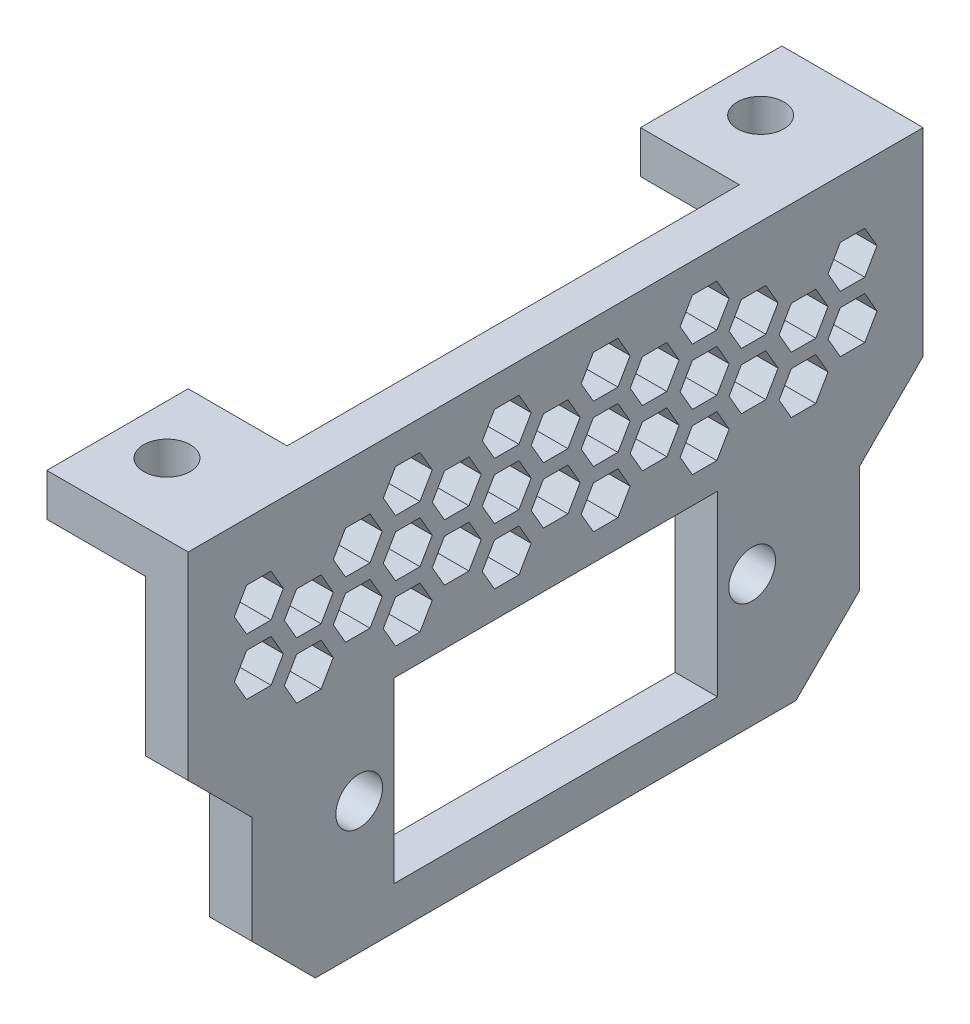
from build123d import *

# Parameters (mm, degrees)
SKETCH1_W           = 34
SKETCH1_H           = 18.6
SKETCH1_R           = 1.65
BOSS_EXTRUDE1_DEPTH = 3
BOSS_EXTRUDE2_DEPTH = 3
SKETCH3_W           = 7
SKETCH3_H           = 10
SKETCH3_R           = 1.65
BOSS_EXTRUDE3_DEPTH = 3
CUT_EXTRUDE1_DEPTH  = 10


with BuildPart() as part:
    # Sketch1 → Boss-Extrude1 (new body)
    with BuildSketch(Plane(origin=(0, 0, 0), x_dir=(0, 0, -1), z_dir=(1, 0, 0))):
        with Locations((0, 6.3)):
            Rectangle(SKETCH1_W, SKETCH1_H)
        with Locations((-13.9, 6.3)):
            Circle(SKETCH1_R, mode=Mode.SUBTRACT)
        Polygon((11.45, 0), (-11.45, 0), (-11.45, 6.3), (-11.45, 12.6), (11.45, 12.6), (11.45, 6.3), align=None, mode=Mode.SUBTRACT)
        with BuildLine():
            ThreePointArc((15.55, 6.3), (13.9, 4.65), (12.25, 6.3))
            ThreePointArc((12.25, 6.3), (13.9, 7.95), (15.55, 6.3))
        make_face(mode=Mode.SUBTRACT)
    extrude(amount=BOSS_EXTRUDE1_DEPTH)

    # Sketch2 → Boss-Extrude2 (add)
    with BuildSketch(Plane.ZY):
        Polygon((-21.5, 9.1), (-21.5, 1.5), (-17, -3), (-17, 15.6), (17, 15.6), (17, -3), (21.5, 1.5), (21.5, 9.1), (26, 13.6), (26, 27.6), (-26, 27.6), (-26, 13.6), align=None)
    extrude(amount=-BOSS_EXTRUDE2_DEPTH)

    # Sketch3 → Boss-Extrude3 (add)
    # profile 1 of 2: a face of its own
    with BuildSketch(Plane(origin=(0, 27.6, 0), x_dir=(1, 0, 0), z_dir=(0, 1, 0))):
        with Locations((-3.5, -21)):
            Rectangle(SKETCH3_W, SKETCH3_H)
        with Locations((-3.5, -21)):
            Circle(SKETCH3_R, mode=Mode.SUBTRACT)
    # profile 2 of 2: a face of its own
    with BuildSketch(Plane(origin=(0, 27.6, 0), x_dir=(1, 0, 0), z_dir=(0, 1, 0))):
        with Locations((-3.5, 21)):
            Rectangle(SKETCH3_W, SKETCH3_H)
        with Locations((-3.5, 21)):
            Circle(SKETCH3_R, mode=Mode.SUBTRACT)
    extrude(amount=-BOSS_EXTRUDE3_DEPTH)

    # Sketch4 → Cut-Extrude1 (cut)
    with BuildSketch(Plane.ZY):
        Polygon((-16.669872981, 18.5), (-15.803847577, 20), (-16.669872981, 21.5), (-18.401923789, 21.5), (-19.267949192, 20), (-18.401923789, 18.5), align=None)
        Polygon((-20.133974596, 16.5), (-19.267949192, 18), (-20.133974596, 19.5), (-21.866025404, 19.5), (-22.732050808, 18), (-21.866025404, 16.5), align=None)
        Polygon((-20.133974596, 20.5), (-19.267949192, 22), (-20.133974596, 23.5), (-21.866025404, 23.5), (-22.732050808, 22), (-21.866025404, 20.5), align=None)
        Polygon((-13.133974596, 16.5), (-12.267949192, 18), (-13.133974596, 19.5), (-14.866025404, 19.5), (-15.732050808, 18), (-14.866025404, 16.5), align=None)
        Polygon((-13.133974596, 20.5), (-12.267949192, 22), (-13.133974596, 23.5), (-14.866025404, 23.5), (-15.732050808, 22), (-14.866025404, 20.5), align=None)
        Polygon((-6.133974596, 16.5), (-5.267949192, 18), (-6.133974596, 19.5), (-7.866025404, 19.5), (-8.732050808, 18), (-7.866025404, 16.5), align=None)
        Polygon((-6.133974596, 20.5), (-5.267949192, 22), (-6.133974596, 23.5), (-7.866025404, 23.5), (-8.732050808, 22), (-7.866025404, 20.5), align=None)
        Polygon((0.866025404, 16.5), (1.732050808, 18), (0.866025404, 19.5), (-0.866025404, 19.5), (-1.732050808, 18), (-0.866025404, 16.5), align=None)
        Polygon((0.866025404, 20.5), (1.732050808, 22), (0.866025404, 23.5), (-0.866025404, 23.5), (-1.732050808, 22), (-0.866025404, 20.5), align=None)
        Polygon((7.866025404, 16.5), (8.732050808, 18), (7.866025404, 19.5), (6.133974596, 19.5), (5.267949192, 18), (6.133974596, 16.5), align=None)
        Polygon((7.866025404, 20.5), (8.732050808, 22), (7.866025404, 23.5), (6.133974596, 23.5), (5.267949192, 22), (6.133974596, 20.5), align=None)
        Polygon((14.866025404, 16.5), (15.732050808, 18), (14.866025404, 19.5), (13.133974596, 19.5), (12.267949192, 18), (13.133974596, 16.5), align=None)
        Polygon((14.866025404, 20.5), (15.732050808, 22), (14.866025404, 23.5), (13.133974596, 23.5), (12.267949192, 22), (13.133974596, 20.5), align=None)
        Polygon((21.866025404, 16.5), (22.732050808, 18), (21.866025404, 19.5), (20.133974596, 19.5), (19.267949192, 18), (20.133974596, 16.5), align=None)
        Polygon((21.866025404, 20.5), (22.732050808, 22), (21.866025404, 23.5), (20.133974596, 23.5), (19.267949192, 22), (20.133974596, 20.5), align=None)
        Polygon((-9.669872981, 18.5), (-8.803847577, 20), (-9.669872981, 21.5), (-11.401923789, 21.5), (-12.267949192, 20), (-11.401923789, 18.5), align=None)
        Polygon((-9.669872981, 22.5), (-8.803847577, 24), (-9.669872981, 25.5), (-11.401923789, 25.5), (-12.267949192, 24), (-11.401923789, 22.5), align=None)
        Polygon((-2.669872981, 18.5), (-1.803847577, 20), (-2.669872981, 21.5), (-4.401923789, 21.5), (-5.267949192, 20), (-4.401923789, 18.5), align=None)
        Polygon((-2.669872981, 22.5), (-1.803847577, 24), (-2.669872981, 25.5), (-4.401923789, 25.5), (-5.267949192, 24), (-4.401923789, 22.5), align=None)
        Polygon((4.330127019, 18.5), (5.196152423, 20), (4.330127019, 21.5), (2.598076211, 21.5), (1.732050808, 20), (2.598076211, 18.5), align=None)
        Polygon((4.330127019, 22.5), (5.196152423, 24), (4.330127019, 25.5), (2.598076211, 25.5), (1.732050808, 24), (2.598076211, 22.5), align=None)
        Polygon((11.330127019, 18.5), (12.196152423, 20), (11.330127019, 21.5), (9.598076211, 21.5), (8.732050808, 20), (9.598076211, 18.5), align=None)
        Polygon((11.330127019, 22.5), (12.196152423, 24), (11.330127019, 25.5), (9.598076211, 25.5), (8.732050808, 24), (9.598076211, 22.5), align=None)
        Polygon((18.330127019, 18.5), (19.196152423, 20), (18.330127019, 21.5), (16.598076211, 21.5), (15.732050808, 20), (16.598076211, 18.5), align=None)
        Polygon((-9.669872981, 14.5), (-8.803847577, 16), (-9.669872981, 17.5), (-11.401923789, 17.5), (-12.267949192, 16), (-11.401923789, 14.5), align=None)
        Polygon((-2.669872981, 14.5), (-1.803847577, 16), (-2.669872981, 17.5), (-4.401923789, 17.5), (-5.267949192, 16), (-4.401923789, 14.5), align=None)
        Polygon((4.330127019, 14.5), (5.196152423, 16), (4.330127019, 17.5), (2.598076211, 17.5), (1.732050808, 16), (2.598076211, 14.5), align=None)
        Polygon((11.330127019, 14.5), (12.196152423, 16), (11.330127019, 17.5), (9.598076211, 17.5), (8.732050808, 16), (9.598076211, 14.5), align=None)
        Polygon((18.330127019, 14.5), (19.196152423, 16), (18.330127019, 17.5), (16.598076211, 17.5), (15.732050808, 16), (16.598076211, 14.5), align=None)
        Polygon((-16.669872981, 14.5), (-15.803847577, 16), (-16.669872981, 17.5), (-18.401923789, 17.5), (-19.267949192, 16), (-18.401923789, 14.5), align=None)
    extrude(amount=-CUT_EXTRUDE1_DEPTH, mode=Mode.SUBTRACT)


solid = part.part
